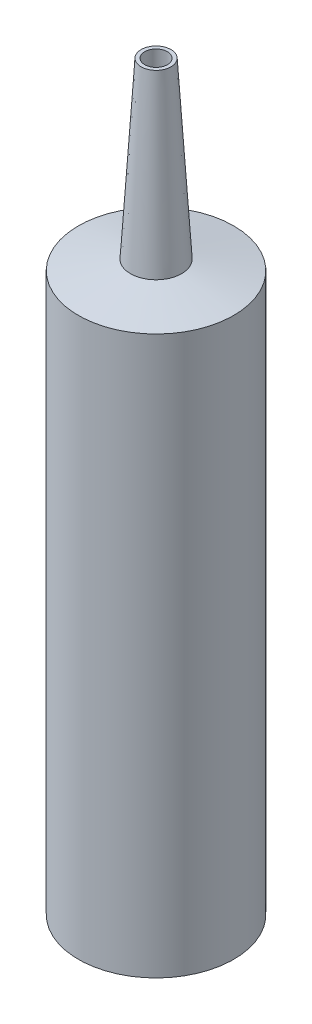
from build123d import *


with BuildPart() as part:
    # 草图1 → 旋转1 (revolve)
    with BuildSketch(Plane.XY):
        Polygon((14.5, 111), (14.5, 0), (15.6, 0), (15.6, 112.036758878), (5.136368561, 114.070682792), (3, 149), (2.276042785, 149), (4.8, 111), align=None)
    revolve(axis=Axis((0, 149, 0), (0, -1, 0)))


solid = part.part
